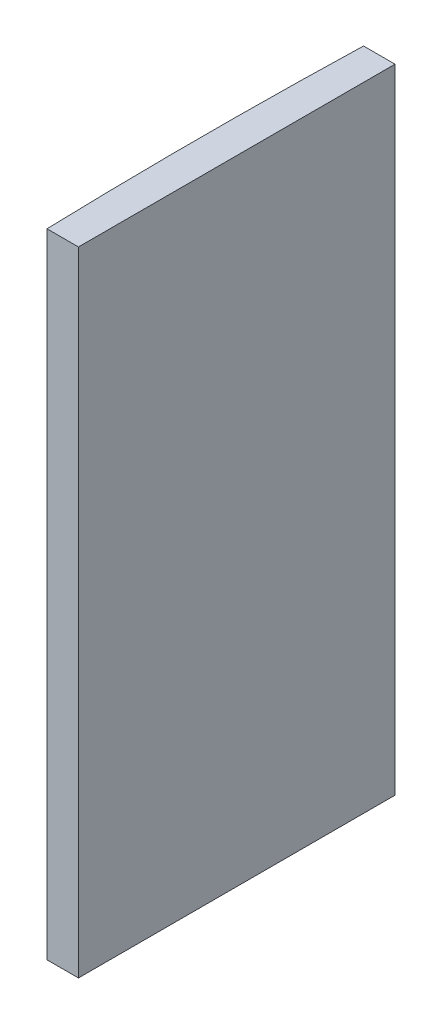
from build123d import *

# Parameters (mm, degrees)
EXTRUDE_1_DEPTH = 60


with BuildPart() as part:
    # 草图1 → 凸台-拉伸1 (new body)
    with BuildSketch(Plane(origin=(0, 0, 0), x_dir=(1, 0, 0), z_dir=(0, 1, 0))):
        with BuildLine():
            Line((-512.227064041, 15), (-509.244795665, 15))
            Line((-509.244795665, 15), (-509.244795665, -15))
            Line((-509.244795665, -15), (-512.227064041, -15))
            ThreePointArc((-512.227064041, -15), (-512.444795665, 0), (-512.227064041, 15))
        make_face()
    extrude(amount=EXTRUDE_1_DEPTH)


solid = part.part
